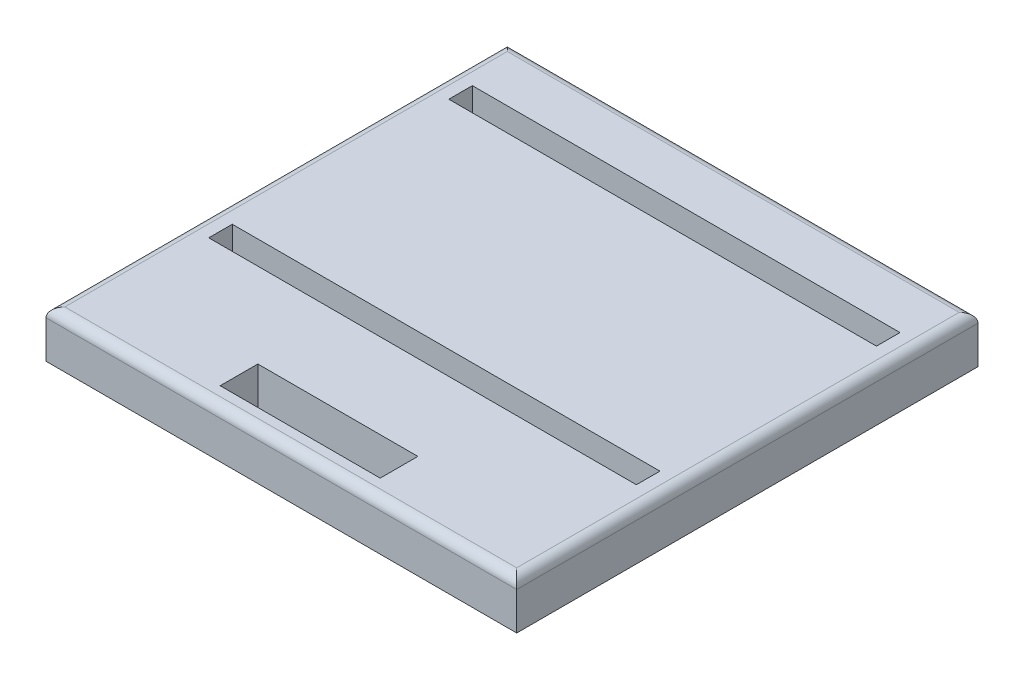
from build123d import *

# Parameters (mm, degrees)
SKETCH2_W           = 127
SKETCH2_H           = 124.46
BOSS_EXTRUDE1_DEPTH = 12.7
FILLET1_R           = 2.54
SKETCH3_W           = 115.38555028
SKETCH3_H           = 6.35
SKETCH3_W_2         = 43.18
SKETCH3_H_2         = 10.16
CUT_EXTRUDE1_DEPTH  = 12.7


with BuildPart() as part:
    # Sketch2 → Boss-Extrude1 (new body)
    with BuildSketch(Plane(origin=(0, 0, 0), x_dir=(1, 0, 0), z_dir=(0, 1, 0))):
        with Locations((0, 19.05)):
            Rectangle(SKETCH2_W, SKETCH2_H)
    extrude(amount=BOSS_EXTRUDE1_DEPTH)

    # Fillet1
    fillet1_edges = [part.edges().sort_by_distance(p)[0] for p in [
        (0, 12.7, 43.18),
        (63.5, 12.7, -19.05),
        (0, 12.7, -81.28),
        (-63.5, 12.7, -19.05),
    ]]
    fillet(fillet1_edges, radius=FILLET1_R)

    # Sketch3 → Cut-Extrude1 (cut)
    with BuildSketch(Plane(origin=(0, 12.7, 0), x_dir=(1, 0, 0), z_dir=(0, 1, 0))):
        with Locations((-2.54e-06, 62.865)):
            Rectangle(SKETCH3_W, SKETCH3_H)
        with Locations((0, -33.02)):
            Rectangle(SKETCH3_W_2, SKETCH3_H_2)
        with Locations((-2.54e-06, -1.905)):
            Rectangle(SKETCH3_W, SKETCH3_H)
    extrude(amount=-CUT_EXTRUDE1_DEPTH, mode=Mode.SUBTRACT)


solid = part.part
